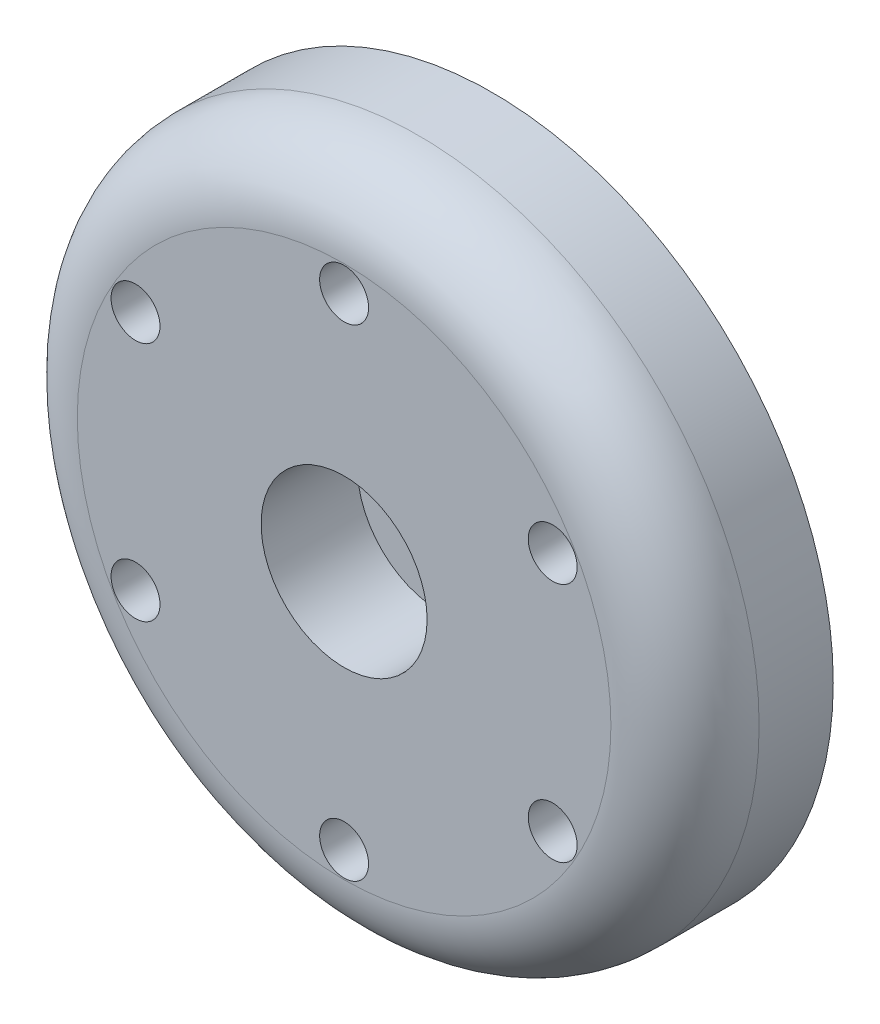
from build123d import *

# Parameters (mm, degrees)
SKETCH1_W                                           = 23
SKETCH1_H                                           = 10
HOLE1_D                                             = 40
HOLE1_DEPTH                                         = 5.8
SKETCH4_W                                           = 12.5
SKETCH4_H                                           = 5.8
F_4_CLEARANCE_HOLE1_D                               = 3.3
F_4_CLEARANCE_HOLE1_DEPTH                           = 10
CBORE_FOR_12_BINDING_HEAD_MACHINE_SCREW_D           = 6.045
CBORE_FOR_12_BINDING_HEAD_MACHINE_SCREW_DEPTH       = 10
CBORE_FOR_12_BINDING_HEAD_MACHINE_SCREW_CBORE_D     = 11.2
CBORE_FOR_12_BINDING_HEAD_MACHINE_SCREW_CBORE_DEPTH = 6.5
FILLET1_R                                           = 5


with BuildPart() as part:
    # Sketch1 → Revolve1 (revolve)
    with BuildSketch(Plane.XZ):
        with Locations((11.5, 5)):
            Rectangle(SKETCH1_W, SKETCH1_H)
    revolve(axis=Axis((0, 0, 10), (0, 0, -1)))

    # Hole1
    with Locations(Plane(origin=(0, 0, 0), x_dir=(-1, 0, 0), z_dir=(0, 0, -1))):
        with Locations((0, 0)):
            Hole(HOLE1_D / 2, depth=HOLE1_DEPTH)

    # Sketch4 → Revolve2 (revolve)
    with BuildSketch(Plane.XZ):
        with Locations((6.25, 2.9)):
            Rectangle(SKETCH4_W, SKETCH4_H)
    revolve(axis=Axis((0, 0, 5.8), (0, 0, -1)))

    # #4 Clearance Hole1
    with Locations(Plane.XY.offset(10)):
        with Locations((14.072912811, 8.125), (14.072912811, -8.125), (0, -16.25), (-14.072912811, -8.125), (-14.072912811, 8.125), (0, 16.25)):
            Hole(F_4_CLEARANCE_HOLE1_D / 2, depth=F_4_CLEARANCE_HOLE1_DEPTH)

    # CBORE for #12 Binding Head Machine Screw1
    with Locations(Plane.XY.offset(10)):
        with Locations((0, 0)):
            CounterBoreHole(CBORE_FOR_12_BINDING_HEAD_MACHINE_SCREW_D / 2, CBORE_FOR_12_BINDING_HEAD_MACHINE_SCREW_CBORE_D / 2, CBORE_FOR_12_BINDING_HEAD_MACHINE_SCREW_CBORE_DEPTH, depth=CBORE_FOR_12_BINDING_HEAD_MACHINE_SCREW_DEPTH)

    # Fillet1
    fillet1_edges = [part.edges().sort_by_distance(p)[0] for p in [
        (-23, 0, 10),
    ]]
    fillet(fillet1_edges, radius=FILLET1_R)


solid = part.part
